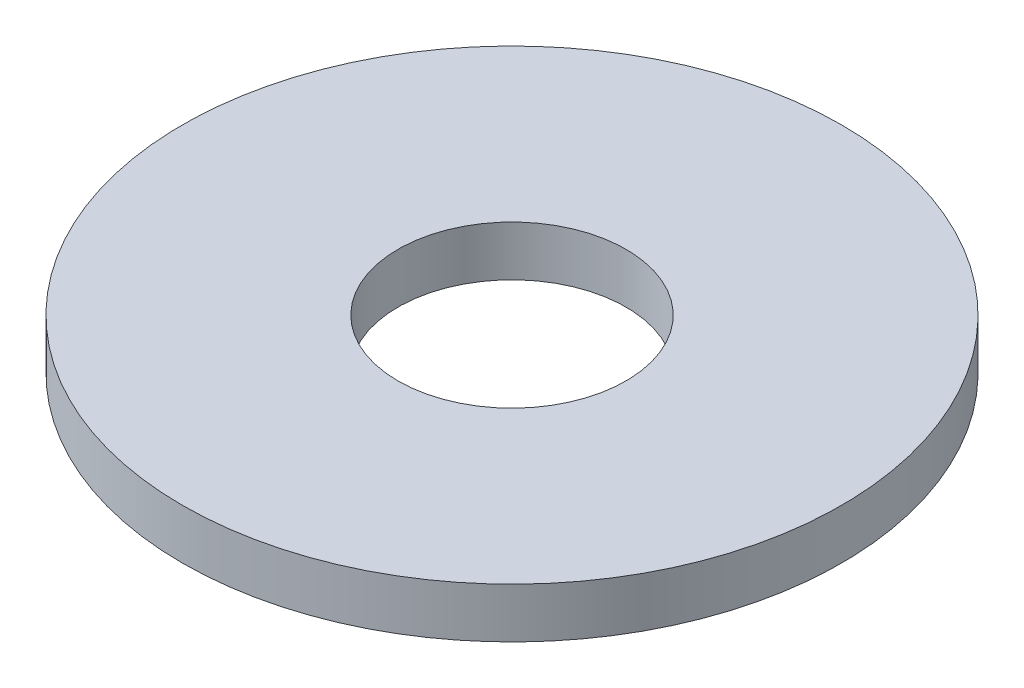
from build123d import *

# Parameters (mm, degrees)
SKETCH1_R           = 11.85
SKETCH1_R_2         = 4.1
BOSS_EXTRUDE1_DEPTH = 1.8


with BuildPart() as part:
    # Sketch1 → Boss-Extrude1 (new body)
    with BuildSketch(Plane(origin=(0, 0, 0), x_dir=(1, 0, 0), z_dir=(0, 1, 0))):
        with Locations(Location((0, 0, 0), (0, 0, 270))):  # turned: the seam where the file's is
            Circle(SKETCH1_R)
        with Locations(Location((0, 0, 0), (0, 0, 270))):  # turned: the seam where the file's is
            Circle(SKETCH1_R_2, mode=Mode.SUBTRACT)
    extrude(amount=BOSS_EXTRUDE1_DEPTH)


solid = part.part
